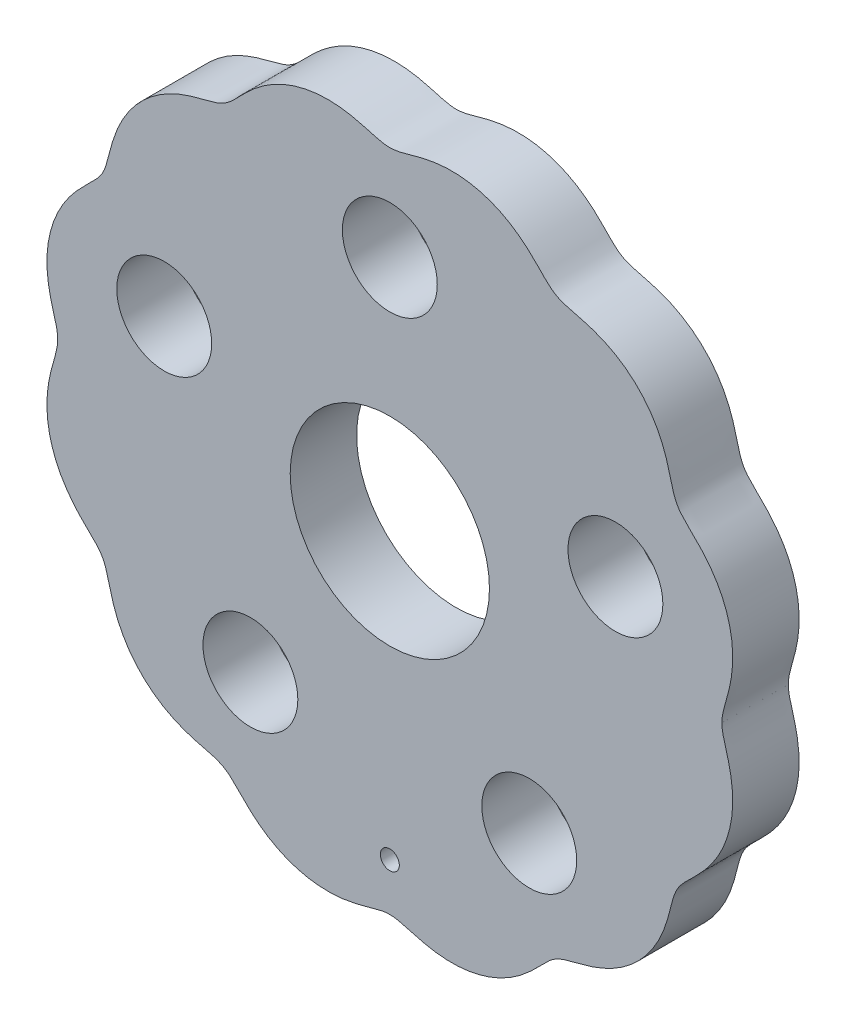
from build123d import *

# Parameters (mm, degrees)
BOSS_EXTRUDE2_DEPTH     = 7
SKETCH3_R               = 10.5
SKETCH3_R_2             = 5
CUT_EXTRUDE1_DEPTH      = 52.585130611
CUT_EXTRUDE1_DEPTH_BACK = 52.585130611
SKETCH4_R               = 1
CUT_EXTRUDE3_DEPTH      = 52.585130611
CUT_EXTRUDE3_DEPTH_BACK = 52.585130611


with BuildPart() as part:
    # Sketch1 → Boss-Extrude2 (new body)
    with BuildSketch(Plane.XY):
        with BuildLine():
            add(Edge.make_bspline(
                [(35, -1e-09), (35, -0.035748813), (35.001174741, -0.106443172), (35.006460851, -0.254691406), (35.020290806, -0.421765972), (35.040411627, -0.586344674), (35.066169832, -0.753201356), (35.104483703, -0.960158501), (35.158713304, -1.206436386), (35.23070995, -1.492053324), (35.319889091, -1.816379491), (35.411987456, -2.140004144), (35.522230647, -2.5274057), (35.646559151, -2.979855302), (35.814079541, -3.645221956), (35.993169468, -4.530765134), (36.126074893, -5.577284833), (36.161566916, -6.787591776), (36.073920835, -8.000177801), (35.847922607, -9.272252293), (35.458234251, -10.584124304), (34.912879602, -11.84026063), (34.222348419, -13.021326943), (33.452097045, -14.064672419), (32.638005801, -14.978595593), (31.800776557, -15.797037086), (30.992274306, -16.561238181), (30.335790971, -17.353195841), (29.954659551, -18.206553476), (29.721064246, -19.057149255), (29.520389712, -19.876560523), (29.29120719, -20.747375681), (28.999522289, -21.662770769), (28.62303256, -22.609753328), (28.140448972, -23.574184953), (27.554800925, -24.522920471), (26.859037082, -25.441153346), (25.957807793, -26.410817168), (24.814710272, -27.37713988), (23.569816068, -28.169500638), (22.25574189, -28.785103627), (21.036001915, -29.21115758), (19.941369596, -29.509105935), (19.007263082, -29.728734488), (18.145443968, -29.980795188), (17.489459792, -30.291858859), (16.891994887, -30.70431031), (16.242738175, -31.324583169), (15.585483067, -32.023729413), (14.780167669, -32.822764851), (13.801371148, -33.666117096), (12.611257978, -34.496411151), (11.302650847, -35.178426225), (9.894275196, -35.685309146), (8.603926614, -35.981050011), (7.460841245, -36.124557527), (6.346390484, -36.157448488), (5.26987209, -36.093228973), (4.261507708, -35.945848008), (3.322898516, -35.740801116), (2.454151769, -35.503903936), (1.644181336, -35.267980259), (0.790764861, -35.044935546), (-0.138806741, -34.948128452), (-1.152942711, -35.120508223), (-2.219017303, -35.438581001), (-3.346413343, -35.75445175), (-4.544925182, -36.002580696), (-5.833606809, -36.14804133), (-7.201702706, -36.155613973), (-8.562238347, -35.999926295), (-9.893213098, -35.681557208), (-11.107895601, -35.2413226), (-12.201871839, -34.711000677), (-13.232344228, -34.075184788), (-14.192186969, -33.345670465), (-14.985765308, -32.624470319), (-15.644015757, -31.955640636), (-16.202030999, -31.374474466), (-16.681344535, -30.902125152), (-17.201714817, -30.472508522), (-17.787699676, -30.134022698), (-18.419879395, -29.897986517), (-19.068580749, -29.718985956), (-19.850890328, -29.52630332), (-20.759253032, -29.290715815), (-21.780652595, -28.964161205), (-22.892408145, -28.497804038), (-23.95835058, -27.923432089), (-24.964701167, -27.241312991), (-25.953406961, -26.409613508), (-26.894743195, -25.416263322), (-27.709984084, -24.315953661), (-28.387629292, -23.127448465), (-28.906137471, -21.938747321), (-29.29063742, -20.77678448), (-29.58084467, -19.64250743), (-29.838399332, -18.560223953), (-30.195844347, -17.595661004), (-30.744148376, -16.838793617), (-31.363957519, -16.211156701), (-31.973243787, -15.627660139), (-32.612825009, -14.993797299), (-33.259770483, -14.28352513), (-33.891684804, -13.484021898), (-34.485670855, -12.583913516), (-35.014539948, -11.602393976), (-35.461940563, -10.540757516), (-35.851163087, -9.27546387), (-36.116571258, -7.802368745), (-36.180424962, -6.328082543), (-36.056605603, -4.882251586), (-35.81577894, -3.612884796), (-35.526535617, -2.515918954), (-35.249687803, -1.597143184), (-35.036994416, -0.724777205), (-34.978249366, -0.001161146), (-35.03656822, 0.722499056), (-35.249036939, 1.594929953), (-35.525889263, 2.513701207), (-35.815258507, 3.610630268), (-36.056294473, 4.879955035), (-36.180383522, 6.325762446), (-36.116818592, 7.80006116), (-35.851701171, 9.273209403), (-35.462729657, 10.538580185), (-35.015537677, 11.60030403), (-34.486860774, 12.581926477), (-33.893041419, 13.482146055), (-33.261271814, 14.281762477), (-32.614423945, 14.992130333), (-31.974916048, 15.626061191), (-31.365607541, 16.209552634), (-30.74570625, 16.837071279), (-30.196923613, 17.593581211), (-29.838971844, 18.55798571), (-29.581381804, 19.640270086), (-29.291266492, 20.774565021), (-28.906961542, 21.936592862), (-28.388663287, 23.125384299), (-27.71125116, 24.314019865), (-26.896225598, 25.414486914), (-25.955089174, 26.408021886), (-24.966548554, 27.239915067), (-23.960333525, 27.922230827), (-22.894500967, 28.496805953), (-21.782830577, 28.963363711), (-20.761478802, 29.290075182), (-19.8531392, 29.525751028), (-19.070822243, 29.718419118), (-18.422093226, 29.897302044), (-17.789809208, 30.133054574), (-17.203619329, 30.471160547), (-16.683028657, 30.900556334), (-16.203669767, 31.372808121), (-15.749813855, 31.845425384), (-15.304135219, 32.301040081), (-14.859312337, 32.732683862), (-14.412691124, 33.136426138), (-13.834069011, 33.617825723), (-13.105982691, 34.153044956), (-12.203903435, 34.709887775), (-11.110029805, 35.240419619), (-9.895432592, 35.680897195), (-8.56451793, 35.999529741), (-7.204011033, 36.155483984), (-5.835911474, 36.148177443), (-4.547203124, 36.002944361), (-3.348650031, 35.755016446), (-2.22122352, 35.439234569), (-1.155167273, 35.121131621), (-0.14114749, 34.948234279), (0.788494246, 35.044447841), (1.641967194, 35.267353395), (2.451930957, 35.50325516), (3.320655503, 35.740249796), (4.259230622, 35.945429029), (5.267569333, 36.092991896), (6.34407475, 36.15741136), (7.458532459, 36.124738287), (8.601646434, 35.981455146), (9.892053677, 35.685970239), (11.300528658, 35.179365694), (12.609269312, 34.497606986), (13.799537711, 33.667534745), (14.778475291, 32.824342775), (15.583885554, 32.025398031), (16.241146923, 31.326253495), (16.890235273, 30.705818725), (17.487448883, 30.293020445), (18.143258036, 29.981565482), (19.00502096, 29.729277488), (19.939125813, 29.509654987), (21.033789234, 29.211834012), (22.253597456, 28.785982305), (23.567786059, 28.17062464), (24.812835451, 27.378507724), (25.956124308, 26.412410279), (26.857545877, 25.442925301), (27.553489696, 24.524829447), (28.139322952, 23.576208944), (28.622086182, 22.611866113), (28.998746314, 21.664952299), (29.290562902, 20.749593918), (29.519841068, 19.878808244), (29.720500124, 19.059380306), (29.953947205, 18.208763871), (30.334529932, 17.355170741), (30.990622265, 16.562853219), (31.799107536, 15.798620905), (32.636398173, 14.980249973), (33.450643196, 14.06646326), (34.221077713, 13.023254245), (34.911838297, 11.842324928), (35.457436926, 10.586295957), (35.847385145, 9.274505295), (36.07363379, 8.002476015), (36.161517809, 6.789910979), (36.126256993, 5.5795939), (35.993540352, 4.533057767), (35.814590418, 3.647474043), (35.647149706, 2.982107194), (35.522856953, 2.529609193), (35.412623714, 2.142278265), (35.320517228, 1.818504466), (35.231303432, 1.494471893), (35.148961187, 1.167599504), (35.087344349, 0.880712203), (35.045777605, 0.629827649), (35.020527431, 0.424354229), (35.006606435, 0.25581412), (35.001237329, 0.110071018), (35.000021225, 0.03805815), (35.000000664, 0.002309249)],
                knots=[0.074965307, 0.074965307, 0.074965307, 0.074965307, 0.074965307, 0.075577409, 0.07618951, 0.076801612, 0.077413713, 0.078025815, 0.078637916, 0.079862119, 0.081086322, 0.082310525, 0.083534728, 0.084758931, 0.086949252, 0.089139572, 0.093520214, 0.097900855, 0.102281497, 0.106733233, 0.111184969, 0.116670702, 0.122156435, 0.126607689, 0.131058942, 0.135510196, 0.139961449, 0.143623392, 0.147285335, 0.15035089, 0.153416445, 0.156482, 0.159547555, 0.163465918, 0.167384282, 0.171302645, 0.175221008, 0.179672994, 0.184124981, 0.19053596, 0.196946939, 0.201072134, 0.205197329, 0.209322524, 0.213447718, 0.215045718, 0.218241717, 0.219839716, 0.223964909, 0.228090101, 0.232215293, 0.236340485, 0.242751468, 0.24916245, 0.253614435, 0.25806642, 0.261984783, 0.265903146, 0.269821509, 0.273739872, 0.276805429, 0.279870986, 0.282936543, 0.286002101, 0.289664044, 0.293325988, 0.297777242, 0.302228496, 0.30667975, 0.311131005, 0.316616734, 0.322102463, 0.326554196, 0.33100593, 0.33538657, 0.339767211, 0.344147851, 0.348528492, 0.3509769, 0.353425308, 0.355873716, 0.358322124, 0.360770528, 0.363218931, 0.365667335, 0.368115739, 0.372496381, 0.376877024, 0.381257666, 0.385638308, 0.390090047, 0.394541786, 0.400027523, 0.40551326, 0.409964513, 0.414415766, 0.418867019, 0.423318272, 0.426980214, 0.430642156, 0.433707709, 0.436773262, 0.439838815, 0.442904368, 0.446822732, 0.450741095, 0.454659458, 0.458577821, 0.463029809, 0.467481797, 0.473892773, 0.480303749, 0.484428946, 0.488554144, 0.492679341, 0.496804538, 0.498402538, 0.501598537, 0.503196537, 0.507321726, 0.511446916, 0.515572105, 0.519697295, 0.526108281, 0.532519267, 0.53697125, 0.541423233, 0.545341596, 0.549259959, 0.553178322, 0.557096685, 0.560162244, 0.563227803, 0.566293362, 0.569358922, 0.573020866, 0.576682811, 0.581134066, 0.58558532, 0.590036575, 0.59448783, 0.599973555, 0.60545928, 0.60991101, 0.614362741, 0.618743381, 0.62312402, 0.62750466, 0.631885299, 0.63433371, 0.63678212, 0.63923053, 0.64167894, 0.644127342, 0.646575744, 0.649024145, 0.651472547, 0.653662869, 0.65585319, 0.658043512, 0.660233833, 0.664614477, 0.66899512, 0.673446862, 0.677898603, 0.683384344, 0.688870085, 0.693321337, 0.69777259, 0.702223842, 0.706675095, 0.710337036, 0.713998977, 0.717064528, 0.720130079, 0.72319563, 0.726261181, 0.730179545, 0.734097908, 0.738016271, 0.741934635, 0.746386624, 0.750838613, 0.757249586, 0.763660559, 0.767785759, 0.771910959, 0.776036159, 0.780161359, 0.781759358, 0.784955357, 0.786553357, 0.790678544, 0.794803731, 0.798928918, 0.803054105, 0.809465094, 0.815876083, 0.820328065, 0.824780046, 0.828698409, 0.832616772, 0.836535135, 0.840453498, 0.843519059, 0.84658462, 0.849650181, 0.852715742, 0.856377688, 0.860039634, 0.864490889, 0.868942144, 0.8733934, 0.877844655, 0.883330376, 0.888816097, 0.893267825, 0.897719553, 0.902100191, 0.90648083, 0.910861468, 0.913051788, 0.915242107, 0.916466313, 0.91769052, 0.918914726, 0.920138932, 0.921363138, 0.922587344, 0.923199447, 0.923811551, 0.924423654, 0.925035757, 0.925035757, 0.925035757, 0.925035757, 0.925035757], degree=4))
            Line((35.000000664, 0.002309249), (35, -1e-09))
        make_face()
    extrude(amount=BOSS_EXTRUDE2_DEPTH)

    # Sketch3 → Cut-Extrude1 (cut, two sides)
    with BuildSketch(Plane.XY.offset(7)) as cut_extrude1_sk:
        Circle(SKETCH3_R)
        with Locations((0, 25.000293877)):
            Circle(SKETCH3_R_2)
        with Locations((23.776692401, 7.725515672)):
            Circle(SKETCH3_R_2)
        with Locations((14.694804044, -20.225662611)):
            Circle(SKETCH3_R_2)
        with Locations((-14.694804044, -20.225662611)):
            Circle(SKETCH3_R_2)
        with Locations((-23.776692401, 7.725515672)):
            Circle(SKETCH3_R_2)
    extrude(amount=CUT_EXTRUDE1_DEPTH, mode=Mode.SUBTRACT)
    extrude(cut_extrude1_sk.sketch, amount=-CUT_EXTRUDE1_DEPTH_BACK, mode=Mode.SUBTRACT)

    # Sketch4 → Cut-Extrude3 (cut, two sides)
    with BuildSketch(Plane.XY.offset(7)) as cut_extrude3_sk:
        with Locations((0, -30)):
            Circle(SKETCH4_R)
    extrude(amount=CUT_EXTRUDE3_DEPTH, mode=Mode.SUBTRACT)
    extrude(cut_extrude3_sk.sketch, amount=-CUT_EXTRUDE3_DEPTH_BACK, mode=Mode.SUBTRACT)


solid = part.part
